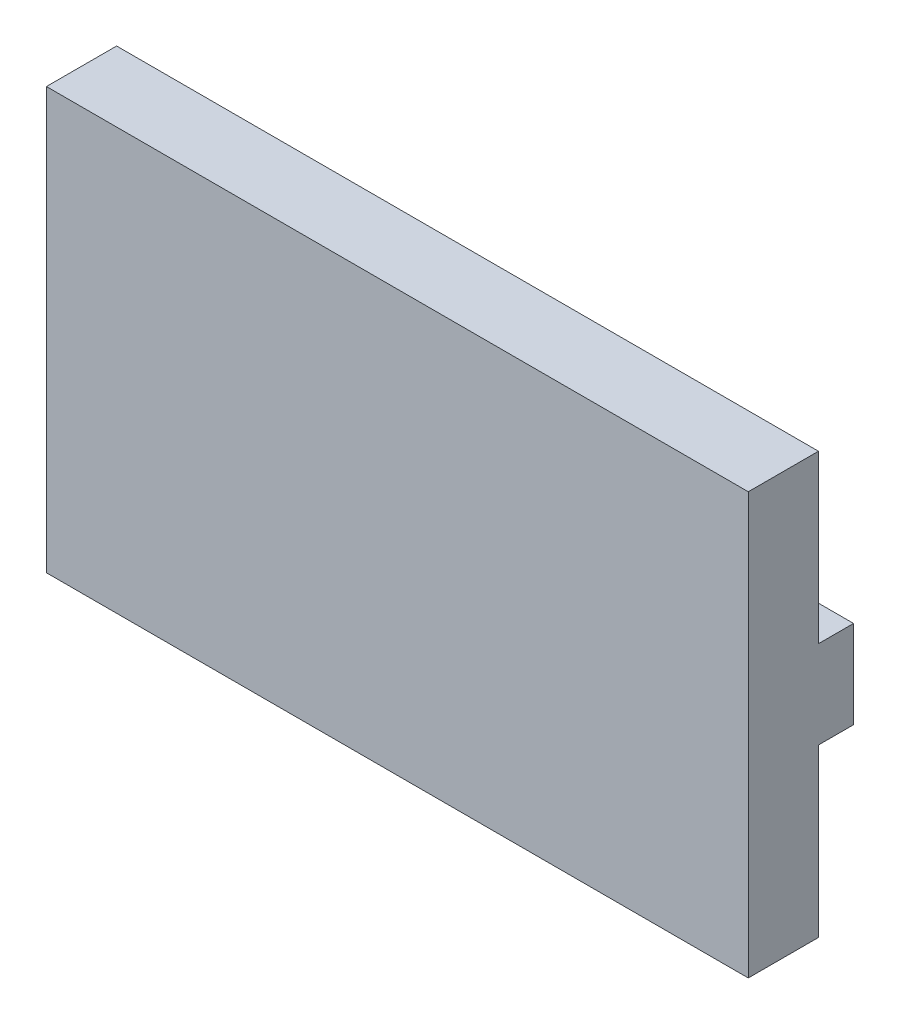
from build123d import *

# Parameters (mm, degrees)
ESQUISSE1_W        = 200
ESQUISSE1_H        = 120
BOSS_EXTRU_1_DEPTH = 20
ESQUISSE2_W        = 20
ESQUISSE2_H        = 25
BOSS_EXTRU_2_DEPTH = 10


with BuildPart() as part:
    # Esquisse1 → Boss.-Extru.1 (new body)
    with BuildSketch(Plane.XY):
        with Locations((109.46747226, 28.673805023)):
            Rectangle(ESQUISSE1_W, ESQUISSE1_H)
    extrude(amount=BOSS_EXTRU_1_DEPTH)

    # Esquisse2 → Boss.-Extru.2 (add)
    with BuildSketch(Plane(origin=(0, 0, 0), x_dir=(-1, 0, 0), z_dir=(0, 0, -1))):
        with Locations((-199.46747226, 28.673805023)):
            Rectangle(ESQUISSE2_W, ESQUISSE2_H)
    extrude(amount=BOSS_EXTRU_2_DEPTH)


solid = part.part
